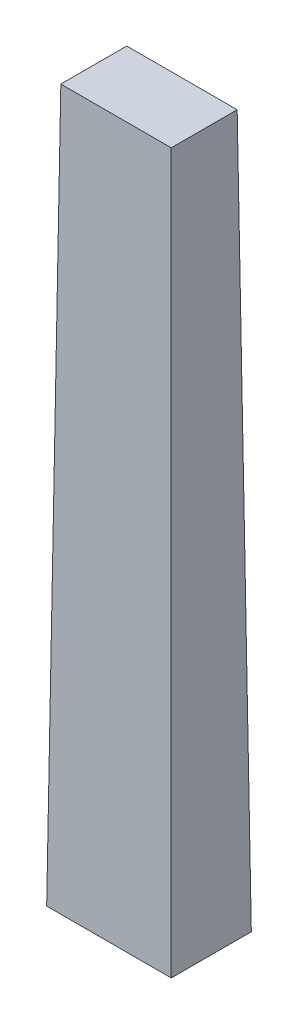
from build123d import *

# Parameters (mm, degrees)
SKETCH1_W           = 14
SKETCH1_H           = 9
BOSS_EXTRUDE3_DEPTH = 80
BOSS_EXTRUDE3_TAPER = 0.57


with BuildPart() as part:
    # Sketch1 → Boss-Extrude3 (new body)
    with BuildSketch(Plane(origin=(0, 0, 0), x_dir=(1, 0, 0), z_dir=(0, 1, 0))):
        with Locations((-1.096049859, 4.683922442)):
            Rectangle(SKETCH1_W, SKETCH1_H)
    extrude(amount=BOSS_EXTRUDE3_DEPTH, taper=BOSS_EXTRUDE3_TAPER)


solid = part.part
